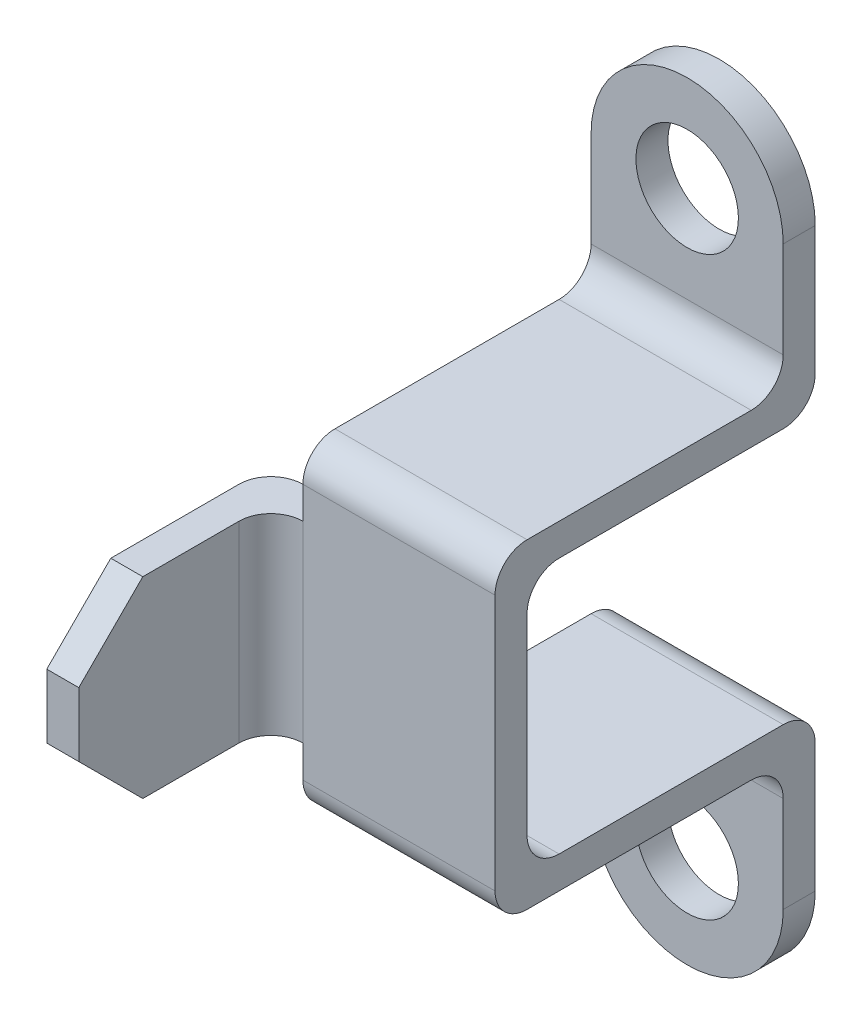
from build123d import *

# Parameters (mm, degrees)
BOSS_EXTRUDE1_DEPTH = 15
FILLET1_R           = 5
FILLET2_R           = 5
SKETCH4_W           = 5
SKETCH4_H           = 5
BOSS_EXTRUDE2_DEPTH = 15
SKETCH6_W           = 15
SKETCH6_H           = 35
BOSS_EXTRUDE3_DEPTH = 5
FILLET3_R           = 5
CHAMFER1_SIZE       = 10
BOSS_EXTRUDE4_DEPTH = 5
SKETCH9_R           = 8
CUT_EXTRUDE6_DEPTH  = 5


with BuildPart() as part:
    # Sketch1 → Boss-Extrude1 (new body, symmetric)
    with BuildSketch(Plane.YZ):
        Polygon((45, 0), (45, 5), (25, 5), (25, 50), (0, 50), (0, 45), (20, 45), (20, 0), align=None)
    extrude(amount=BOSS_EXTRUDE1_DEPTH, both=True)

    # Fillet1
    fillet1_edges = [part.edges().sort_by_distance(p)[0] for p in [
        (0, 25, 5),
    ]]
    fillet(fillet1_edges, radius=FILLET1_R)

    # Fillet2
    fillet2_edges = [part.edges().sort_by_distance(p)[0] for p in [
        (0, 20, 0),
        (0, 20, 45),
        (0, 25, 50),
    ]]
    fillet(fillet2_edges, radius=FILLET2_R)

    # Sketch4 → Boss-Extrude2 (add)
    with BuildSketch(Plane(origin=(0, 0, 0), x_dir=(-1, 0, 0), z_dir=(0, 1, 0))):
        with Locations((17.5, 47.5)):
            Rectangle(SKETCH4_W, SKETCH4_H)
    extrude(amount=BOSS_EXTRUDE2_DEPTH)

    # Sketch6 → Boss-Extrude3 (add)
    with BuildSketch(Plane(origin=(-20, 0, 0), x_dir=(0, -1, 0), z_dir=(-1, 0, 0))):
        with Locations((-7.5, 62.5)):
            Rectangle(SKETCH6_W, SKETCH6_H)
    extrude(amount=BOSS_EXTRUDE3_DEPTH)

    # Fillet3
    fillet3_edges = [part.edges().sort_by_distance(p)[0] for p in [
        (-25, 7.5, 45),
        (-20, 7.5, 50),
    ]]
    fillet(fillet3_edges, radius=FILLET3_R)

    # Chamfer1
    chamfer1_edges = [part.edges().sort_by_distance(p)[0] for p in [
        (-22.5, 15, 80),
    ]]
    chamfer(chamfer1_edges, length=CHAMFER1_SIZE)

    # Sketch8 → Boss-Extrude4 (add)
    with BuildSketch(Plane.XY.offset(5)):
        with BuildLine():
            Line((-15, 45), (15, 45))
            ThreePointArc((15, 45), (0, 60), (-15, 45))
        make_face()
    extrude(amount=-BOSS_EXTRUDE4_DEPTH)

    # Sketch9 → Cut-Extrude6 (cut)
    with BuildSketch(Plane.XY.offset(5)):
        with Locations((0, 45)):
            Circle(SKETCH9_R)
    extrude(amount=-CUT_EXTRUDE6_DEPTH, mode=Mode.SUBTRACT)

    # Mirror2: part across plane


with BuildPart() as part_1:
    add(part.part)
    add(part.part.mirror(Plane(origin=(15, 0, 50), x_dir=(0, 0, 1), z_dir=(0, 1, 0))))


solid = part_1.part
